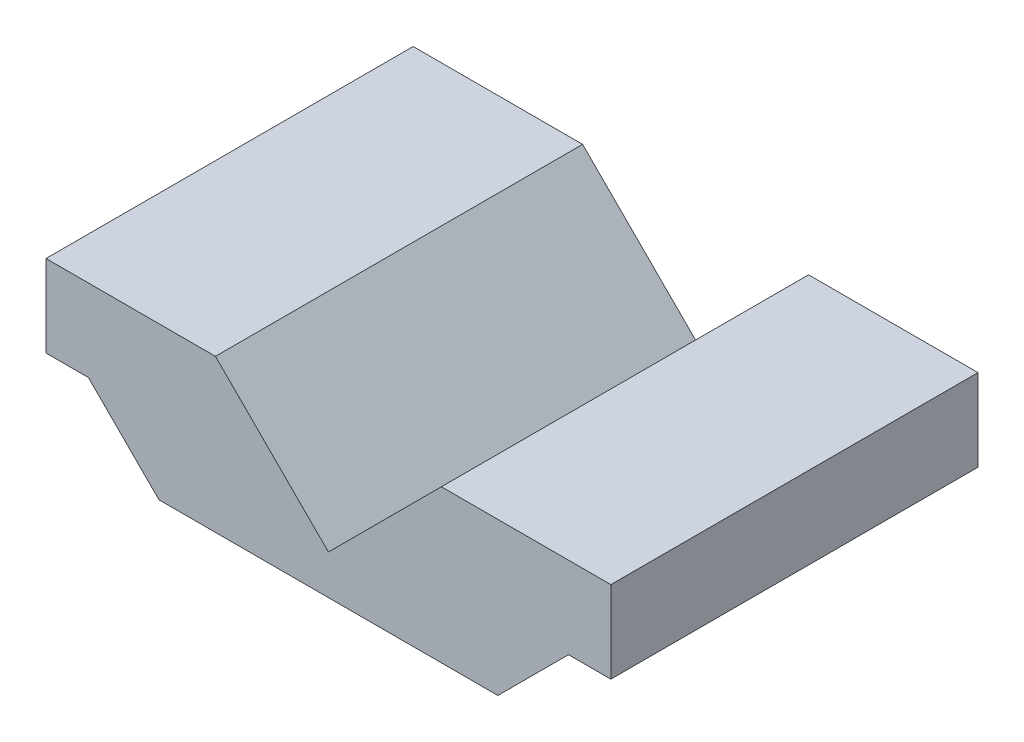
from build123d import *

# Parameters (mm, degrees)
SALIENTE_EXTRUIR1_DEPTH = 32.5


with BuildPart() as part:
    # Croquis1 → Saliente-Extruir1 (new body, symmetric)
    with BuildSketch(Plane.XY):
        Polygon((-30, 0), (30, 0), (42.5, 12.5), (50, 12.5), (50, 27), (20, 27), (0, 7), (-20, 27), (-50, 27), (-50, 12.5), (-42.5, 12.5), align=None)
    extrude(amount=SALIENTE_EXTRUIR1_DEPTH, both=True)


solid = part.part
